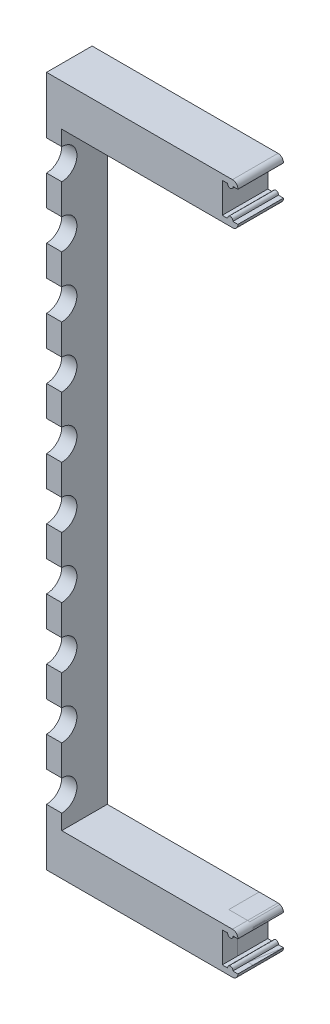
from build123d import *

# Parameters (mm, degrees)
BOSS_EXTRUDE1_DEPTH = 10
BOSS_EXTRUDE2_DEPTH = 15
CUT_EXTRUDE4_DEPTH  = 5


with BuildPart() as part:
    # Sketch4 → Boss-Extrude1 (new body)
    with BuildSketch(Plane.XY):
        with BuildLine():
            Line((0, 13.7), (0, 0))
            Line((0, 0), (6.2, 0))
            ThreePointArc((6.2, 0), (7.472792206, 0.527207794), (8, 1.8))
            Line((8, 1.8), (8, 1.85))
            Line((8, 1.85), (6.336660027, 1.85))
            Line((6.336660027, 1.85), (4.663339973, 1.85))
            Line((4.663339973, 1.85), (2.85, 1.85))
            Line((2.85, 1.85), (2.85, 11.85))
            Line((2.85, 11.85), (4.663339973, 11.85))
            Line((4.663339973, 11.85), (6.336660027, 11.85))
            Line((6.336660027, 11.85), (8, 11.85))
            Line((8, 11.85), (8, 11.9))
            ThreePointArc((8, 11.9), (7.472792206, 13.172792206), (6.2, 13.7))
            Line((6.2, 13.7), (0, 13.7))
        make_face()
        with BuildLine():
            ThreePointArc((4.663339973, 11.85), (5.5, 10.85), (6.336660027, 11.85))
            Line((6.336660027, 11.85), (4.663339973, 11.85))
        make_face()
        with BuildLine():
            Line((4.663339973, 1.85), (6.336660027, 1.85))
            ThreePointArc((6.336660027, 1.85), (5.5, 2.85), (4.663339973, 1.85))
        make_face()
    extrude(amount=BOSS_EXTRUDE1_DEPTH)


with BuildPart() as body_2:
    # Sketch4_5 → Boss-Extrude2 (new body)
    with BuildSketch(Plane.XY):
        with BuildLine():
            Line((0, 13.7), (0, 0))
            Line((0, 0), (6.2, 0))
            ThreePointArc((6.2, 0), (7.472792206, 0.527207794), (8, 1.8))
            Line((8, 1.8), (8, 1.85))
            Line((8, 1.85), (6.336660027, 1.85))
            Line((6.336660027, 1.85), (4.663339973, 1.85))
            Line((4.663339973, 1.85), (2.85, 1.85))
            Line((2.85, 1.85), (2.85, 11.85))
            Line((2.85, 11.85), (4.663339973, 11.85))
            Line((4.663339973, 11.85), (6.336660027, 11.85))
            Line((6.336660027, 11.85), (8, 11.85))
            Line((8, 11.85), (8, 11.9))
            ThreePointArc((8, 11.9), (7.472792206, 13.172792206), (6.2, 13.7))
            Line((6.2, 13.7), (0, 13.7))
        make_face()
        Polygon((-55, 0), (0, 0), (0, 13.7), (-50, 13.7), (-50, 113.7), (-55, 113.7), align=None)
        Polygon((-55, 227.4), (-55, 113.7), (-50, 113.7), (-50, 213.7), (0, 213.7), (0, 227.4), align=None)
        with BuildLine():
            Line((6.2, 227.4), (0, 227.4))
            Line((0, 227.4), (0, 213.7))
            Line((0, 213.7), (6.2, 213.7))
            ThreePointArc((6.2, 213.7), (7.472792206, 214.227207794), (8, 215.5))
            Line((8, 215.5), (8, 215.55))
            Line((8, 215.55), (6.336660027, 215.55))
            Line((6.336660027, 215.55), (4.663339973, 215.55))
            Line((4.663339973, 215.55), (2.85, 215.55))
            Line((2.85, 215.55), (2.85, 225.55))
            Line((2.85, 225.55), (4.663339973, 225.55))
            Line((4.663339973, 225.55), (6.336660027, 225.55))
            Line((6.336660027, 225.55), (8, 225.55))
            Line((8, 225.55), (8, 225.6))
            ThreePointArc((8, 225.6), (7.472792206, 226.872792206), (6.2, 227.4))
        make_face()
        with BuildLine():
            ThreePointArc((4.663339973, 225.55), (5.5, 224.55), (6.336660027, 225.55))
            Line((6.336660027, 225.55), (4.663339973, 225.55))
        make_face()
        with BuildLine():
            Line((4.663339973, 215.55), (6.336660027, 215.55))
            ThreePointArc((6.336660027, 215.55), (5.5, 216.55), (4.663339973, 215.55))
        make_face()
        with BuildLine():
            Line((4.663339973, 1.85), (6.336660027, 1.85))
            ThreePointArc((6.336660027, 1.85), (5.5, 2.85), (4.663339973, 1.85))
        make_face()
        with BuildLine():
            ThreePointArc((4.663339973, 11.85), (5.5, 10.85), (6.336660027, 11.85))
            Line((6.336660027, 11.85), (4.663339973, 11.85))
        make_face()
    extrude(amount=BOSS_EXTRUDE2_DEPTH)

    # Sketch5 → Cut-Extrude4 (cut)
    with BuildSketch(Plane.ZY.offset(55)):
        with BuildLine():
            Line((15, 88.7), (15, 78.7))
            ThreePointArc((15, 78.7), (10, 83.7), (15, 88.7))
        make_face()
        with BuildLine():
            Line((15, 108.7), (15, 98.7))
            ThreePointArc((15, 98.7), (10, 103.7), (15, 108.7))
        make_face()
        with BuildLine():
            Line((15, 68.7), (15, 58.7))
            ThreePointArc((15, 58.7), (10, 63.7), (15, 68.7))
        make_face()
        with BuildLine():
            Line((15, 48.7), (15, 38.7))
            ThreePointArc((15, 38.7), (10, 43.7), (15, 48.7))
        make_face()
        with BuildLine():
            Line((15, 28.7), (15, 18.7))
            ThreePointArc((15, 18.7), (10, 23.7), (15, 28.7))
        make_face()
        with BuildLine():
            Line((15, 118.7), (15, 128.7))
            ThreePointArc((15, 128.7), (10, 123.7), (15, 118.7))
        make_face()
        with BuildLine():
            Line((15, 198.7), (15, 208.7))
            ThreePointArc((15, 208.7), (10, 203.7), (15, 198.7))
        make_face()
        with BuildLine():
            Line((15, 178.7), (15, 188.7))
            ThreePointArc((15, 188.7), (10, 183.7), (15, 178.7))
        make_face()
        with BuildLine():
            Line((15, 158.7), (15, 168.7))
            ThreePointArc((15, 168.7), (10, 163.7), (15, 158.7))
        make_face()
        with BuildLine():
            Line((15, 138.7), (15, 148.7))
            ThreePointArc((15, 148.7), (10, 143.7), (15, 138.7))
        make_face()
    extrude(amount=-CUT_EXTRUDE4_DEPTH, mode=Mode.SUBTRACT)


solid = Compound([part.part, body_2.part])
